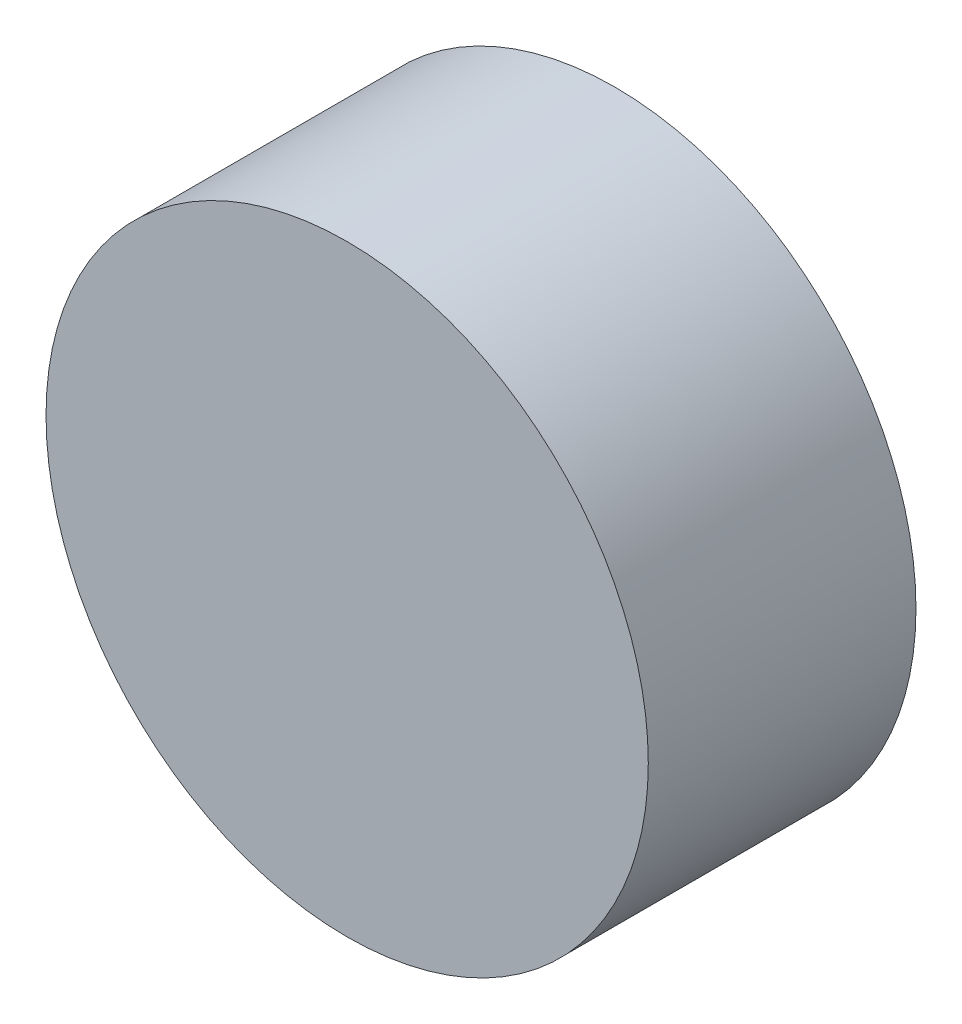
from build123d import *

# Parameters (mm, degrees)
SKETCH1_R           = 4.5
BOSS_EXTRUDE1_DEPTH = 4
SKETCH2_R           = 2.5
CUT_EXTRUDE1_DEPTH  = 3


with BuildPart() as part:
    # Sketch1 → Boss-Extrude1 (new body)
    with BuildSketch(Plane.XY):
        Circle(SKETCH1_R)
    extrude(amount=BOSS_EXTRUDE1_DEPTH)

    # Sketch2 → Cut-Extrude1 (cut)
    with BuildSketch(Plane(origin=(0, 0, 0), x_dir=(-1, 0, 0), z_dir=(0, 0, -1))):
        Circle(SKETCH2_R)
    extrude(amount=-CUT_EXTRUDE1_DEPTH, mode=Mode.SUBTRACT)


solid = part.part
